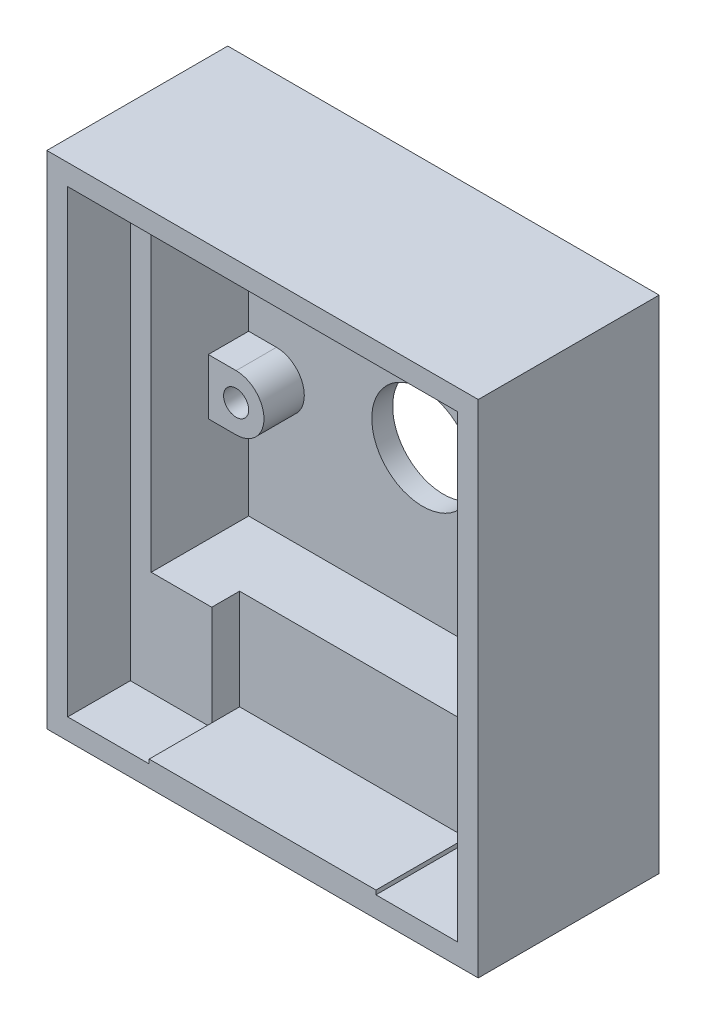
from build123d import *

# Parameters (mm, degrees)
CROQUIS1_W               = 25
CROQUIS1_H               = 24
CROQUIS1_R               = 3.65
SALIENTE_EXTRUIR1_DEPTH  = 1.5
SALIENTE_EXTRUIR7_DEPTH  = 8.5
CROQUIS2_R               = 0.9
SALIENTE_EXTRUIR2_DEPTH  = 2.9
CROQUIS5_W               = 31
CROQUIS5_H               = 9
SALIENTE_EXTRUIR8_DEPTH  = 6.5
CROQUIS6_R               = 2.65
CORTAR_EXTRUIR1_DEPTH    = 6.5
SALIENTE_EXTRUIR9_DEPTH  = 2
CROQUIS8_W               = 31
CROQUIS8_H               = 36
SALIENTE_EXTRUIR10_DEPTH = 4.5
CROQUIS9_W               = 5.85
CROQUIS9_H               = 7.5
CORTAR_EXTRUIR3_DEPTH    = 2


with BuildPart() as part:
    # Croquis1 → Saliente-Extruir1 (new body)
    with BuildSketch(Plane.XY):
        with Locations((0, 1.5)):
            Rectangle(CROQUIS1_W, CROQUIS1_H)
        Circle(CROQUIS1_R, mode=Mode.SUBTRACT)
    extrude(amount=SALIENTE_EXTRUIR1_DEPTH)

    # Croquis4 → Saliente-Extruir7 (add)
    with BuildSketch(Plane(origin=(0, 0, 0), x_dir=(-1, 0, 0), z_dir=(0, 0, -1))):
        Polygon((12.5, -10.5), (12.5, 13.5), (-12.5, 13.5), (-12.5, -10.5), (-15.5, -10.5), (-15.5, 16.5), (15.5, 16.5), (15.5, -10.5), align=None)
    extrude(amount=-SALIENTE_EXTRUIR7_DEPTH)

    # Croquis2 → Saliente-Extruir2 (add)
    with BuildSketch(Plane.XY.offset(1.5)):
        with BuildLine():
            Line((-10.5, 9.5), (-12.5, 9.5))
            Line((-12.5, 9.5), (-12.5, 13.5))
            Line((-12.5, 13.5), (-10.5, 13.5))
            ThreePointArc((-10.5, 13.5), (-8.5, 11.5), (-10.5, 9.5))
        make_face()
        with Locations((-10.5, 11.5)):
            Circle(CROQUIS2_R, mode=Mode.SUBTRACT)
        with BuildLine():
            Line((-10.5, -3), (-12.5, -3))
            Line((-12.5, -3), (-12.5, 1))
            Line((-12.5, 1), (-10.5, 1))
            ThreePointArc((-10.5, 1), (-8.5, -1), (-10.5, -3))
        make_face()
        with Locations((-10.5, -1)):
            Circle(CROQUIS2_R, mode=Mode.SUBTRACT)
    saliente_extruir2 = extrude(amount=SALIENTE_EXTRUIR2_DEPTH)

    # Simetría2: Saliente-Extruir2 across plane
    add(saliente_extruir2.mirror(Plane(origin=(0, 0, 0), x_dir=(0, 0, 1), z_dir=(1, 0, 0))))

    # Croquis5 → Saliente-Extruir8 (add)
    with BuildSketch(Plane(origin=(0, 0, 0), x_dir=(-1, 0, 0), z_dir=(0, 0, -1))):
        with Locations((0, -15)):
            Rectangle(CROQUIS5_W, CROQUIS5_H)
    extrude(amount=-SALIENTE_EXTRUIR8_DEPTH)

    # Croquis6 → Cortar-Extruir1 (cut)
    with BuildSketch(Plane.XY.offset(6.5)):
        with Locations((10.8, -14.15)):
            Circle(CROQUIS6_R)
    extrude(amount=-CORTAR_EXTRUIR1_DEPTH, mode=Mode.SUBTRACT)

    # Croquis7 → Saliente-Extruir9 (add)
    with BuildSketch(Plane.XY.offset(6.5)):
        with BuildLine():
            Line((-15.5, -10.5), (-8.15, -10.5))
            Line((-8.15, -10.5), (-8.15, -17.7))
            Line((-8.15, -17.7), (8.15, -17.7))
            Line((8.15, -17.7), (8.15, -14.768763357))
            Line((8.15, -14.768763357), (8.223251679, -14.768763357))
            ThreePointArc((8.223251679, -14.768763357), (13.448478088, -14.239798753), (8.271080496, -13.35812492))
            Line((8.271080496, -13.35812492), (8.15, -13.35812492))
            Line((8.15, -13.35812492), (8.15, -10.5))
            Line((8.15, -10.5), (15.5, -10.5))
            Line((15.5, -10.5), (15.5, -19.5))
            Line((15.5, -19.5), (8.15, -19.5))
            Line((8.15, -19.5), (-8.15, -19.5))
            Line((-8.15, -19.5), (-15.5, -19.5))
            Line((-15.5, -19.5), (-15.5, -10.5))
        make_face()
    extrude(amount=SALIENTE_EXTRUIR9_DEPTH)

    # Croquis8 → Saliente-Extruir10 (add)
    with BuildSketch(Plane.XY.offset(8.5)):
        with Locations((0, -1.5)):
            Rectangle(CROQUIS8_W, CROQUIS8_H)
        Polygon((-14, 15), (14, 15), (14, -18), (8.15, -18), (8.15, -17.7), (-8.15, -17.7), (-8.15, -18), (-14, -18), align=None, mode=Mode.SUBTRACT)
    extrude(amount=SALIENTE_EXTRUIR10_DEPTH)

    # Croquis9 → Cortar-Extruir3 (cut)
    with BuildSketch(Plane.XY.offset(8.5)):
        with Locations((11.075, -14.25)):
            Rectangle(CROQUIS9_W, CROQUIS9_H)
    extrude(amount=-CORTAR_EXTRUIR3_DEPTH, mode=Mode.SUBTRACT)


solid = part.part
